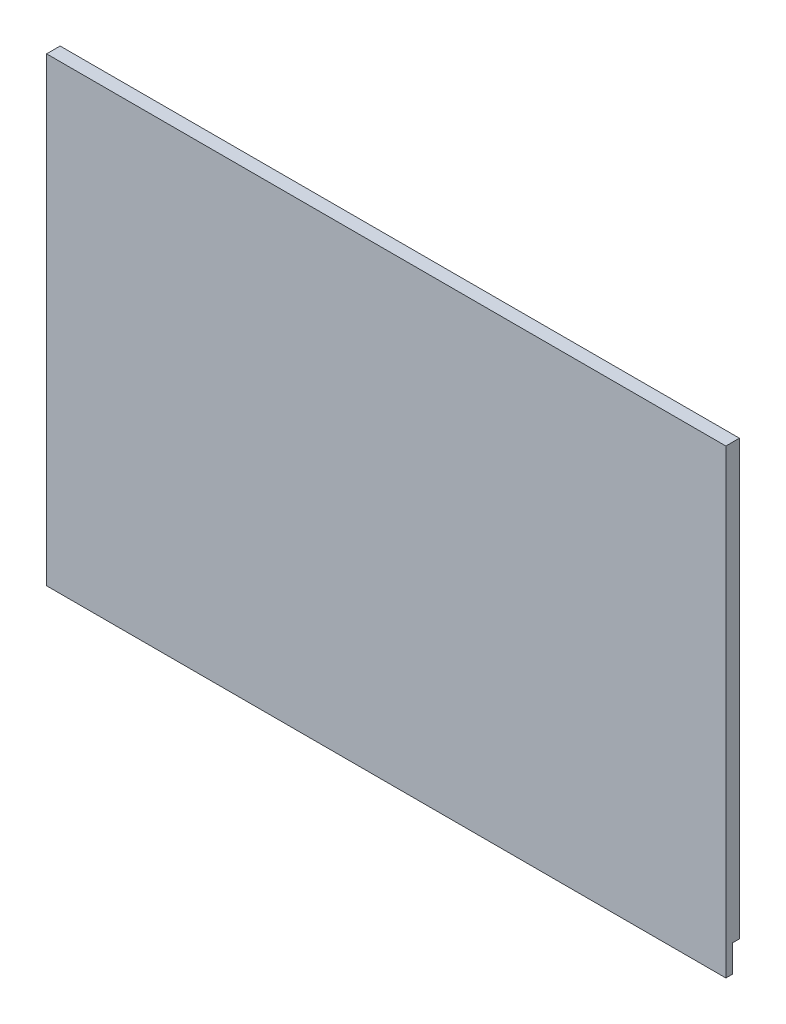
from build123d import *

# Parameters (mm, degrees)
SKETCH1_W           = 159.1564
SKETCH1_H           = 107.95
BOSS_EXTRUDE1_DEPTH = 3.175
SKETCH2_W           = 159.1564
SKETCH2_H           = 6.35
CUT_EXTRUDE1_DEPTH  = 1.5875


with BuildPart() as part:
    # Sketch1 → Boss-Extrude1 (new body)
    with BuildSketch(Plane.XY):
        with Locations((-79.5782, 53.975)):
            Rectangle(SKETCH1_W, SKETCH1_H)
    extrude(amount=BOSS_EXTRUDE1_DEPTH)

    # Sketch2 → Cut-Extrude1 (cut)
    with BuildSketch(Plane(origin=(0, 0, 0), x_dir=(-1, 0, 0), z_dir=(0, 0, -1))):
        with Locations((79.5782, 3.175)):
            Rectangle(SKETCH2_W, SKETCH2_H)
    extrude(amount=-CUT_EXTRUDE1_DEPTH, mode=Mode.SUBTRACT)


solid = part.part
